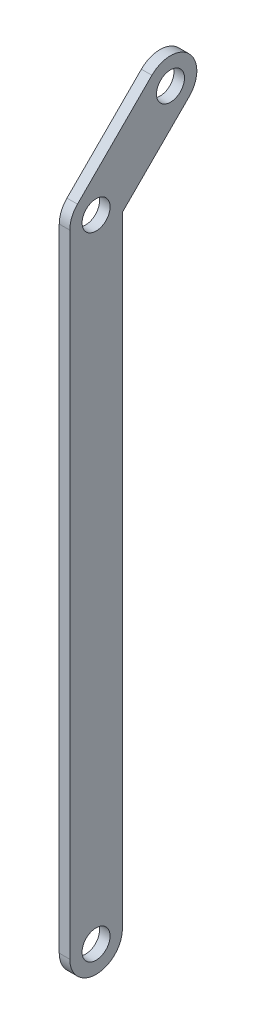
from build123d import *

# Parameters (mm, degrees)
BOSS_EXTRUDE1_DEPTH         = 2.54
F_1_4_CLEARANCE_HOLE2_D     = 6.7564
F_1_4_CLEARANCE_HOLE2_DEPTH = 8.382
F_1_4_CLEARANCE_HOLE2_TIP   = 2.029827343


with BuildPart() as part:
    # Sketch1 → Boss-Extrude1 (new body)
    with BuildSketch(Plane(origin=(0, 0, 0), x_dir=(0, 0, -1), z_dir=(1, 0, 0))):
        with BuildLine():
            Line((6.35, -2.630256121), (6.35, -152.4))
            ThreePointArc((6.35, -152.4), (0, -158.75), (-6.35, -152.4))
            Line((-6.35, -152.4), (-6.35, 0))
            ThreePointArc((-6.35, 0), (-5.866635031, 2.430039796), (-4.490128061, 4.490128061))
            Line((-4.490128061, 4.490128061), (13.470384182, 22.450640303))
            ThreePointArc((13.470384182, 22.450640303), (22.450640303, 22.450640303), (22.450640303, 13.470384182))
            Line((22.450640303, 13.470384182), (6.35, -2.630256121))
        make_face()
    extrude(amount=BOSS_EXTRUDE1_DEPTH)

    # 1/4 Clearance Hole2
    with Locations(Plane(origin=(2.54, 0, 0), x_dir=(0, 0, -1), z_dir=(1, 0, 0))):
        with Locations((0, 0), (0, -152.4), (17.960512242, 17.960512242)):
            Hole(F_1_4_CLEARANCE_HOLE2_D / 2, depth=F_1_4_CLEARANCE_HOLE2_DEPTH)
            with Locations((0, 0, -(F_1_4_CLEARANCE_HOLE2_DEPTH + F_1_4_CLEARANCE_HOLE2_TIP / 2))):  # 118° drill point
                Cone(0, F_1_4_CLEARANCE_HOLE2_D / 2, F_1_4_CLEARANCE_HOLE2_TIP, mode=Mode.SUBTRACT)


solid = part.part
